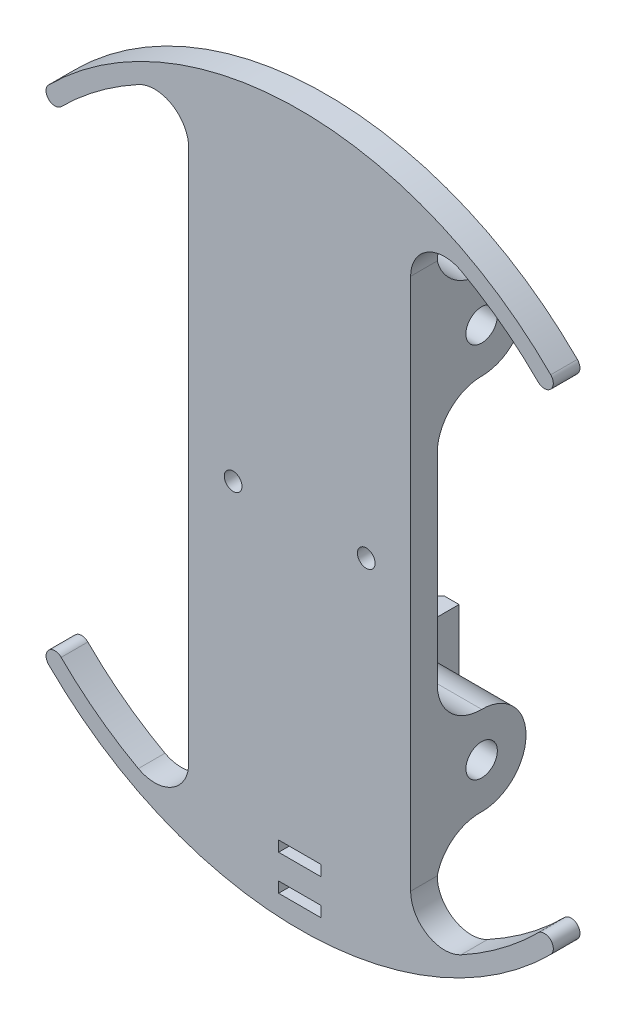
from build123d import *

# Parameters (mm, degrees)
MAIN_BODY_DEPTH                  = 3.81
CROSS_SCREW_BOSSES_DEPTH         = 31.75
F_8_CLEARANCE_HOLE1_D            = 4.4958
BALLOON_MONOFILAMENT_HOLE_D      = 2.5273
PARACHUTE_MONOFILAMENT_HOLE_D    = 2.5273
SKETCH21_W                       = 12.08
SKETCH21_H                       = 11.74
HOT_WIRE_CUTTER_HOLDER_DEPTH     = 9.67
CUT_EXTRUDE10_START              = -1.27
CUT_EXTRUDE10_DEPTH              = 63.383576094
CHAMFER8_SIZE                    = 0.381
SKETCH22_W                       = 6.029522694
SKETCH22_H                       = 1.524
SATELLITE_CABLE_MANAGEMENT_DEPTH = 66.050272386


with BuildPart() as part:
    # Sketch3 → Main body (new body)
    with BuildSketch(Plane.XY):
        with BuildLine():
            Line((-15.875, -38.1), (-15.875, 38.1))
            ThreePointArc((-15.875, 38.1), (-18.260491841, 42.291797068), (-23.082694008, 42.38179842))
            ThreePointArc((-23.082694008, 42.38179842), (-28.900226452, 38.649767283), (-34.12497326, 34.12497326))
            ThreePointArc((-34.12497326, 34.12497326), (-35.921024484, 34.12497326), (-35.921024484, 35.921024484))
            ThreePointArc((-35.921024484, 35.921024484), (0, 50.8), (35.921024484, 35.921024484))
            ThreePointArc((35.921024484, 35.921024484), (35.921024484, 34.12497326), (34.12497326, 34.12497326))
            ThreePointArc((34.12497326, 34.12497326), (28.900226452, 38.649767283), (23.082694008, 42.38179842))
            ThreePointArc((23.082694008, 42.38179842), (18.260491841, 42.291797068), (15.875, 38.1))
            Line((15.875, 38.1), (15.875, -38.1))
            ThreePointArc((15.875, -38.1), (18.260491841, -42.291797068), (23.082694008, -42.38179842))
            ThreePointArc((23.082694008, -42.38179842), (28.900226452, -38.649767283), (34.12497326, -34.12497326))
            ThreePointArc((34.12497326, -34.12497326), (35.921024484, -34.12497326), (35.921024484, -35.921024484))
            ThreePointArc((35.921024484, -35.921024484), (0, -50.8), (-35.921024484, -35.921024484))
            ThreePointArc((-35.921024484, -35.921024484), (-35.921024484, -34.12497326), (-34.12497326, -34.12497326))
            ThreePointArc((-34.12497326, -34.12497326), (-28.900226452, -38.649767283), (-23.082694008, -42.38179842))
            ThreePointArc((-23.082694008, -42.38179842), (-18.260491841, -42.291797068), (-15.875, -38.1))
        make_face()
    extrude(amount=MAIN_BODY_DEPTH)

    # Sketch5 → Cross screw bosses (add)
    with BuildSketch(Plane(origin=(15.875, 0, 0), x_dir=(0, 0, -1), z_dir=(1, 0, 0))):
        with BuildLine():
            Line((0, 38.1), (0, 26.99385))
            Line((0, 26.99385), (0, 14.29385))
            ThreePointArc((0, 14.29385), (1.86498297, 18.77886703), (6.35, 20.64385))
            ThreePointArc((6.35, 20.64385), (12.699998494, 26.998224058), (6.341251887, 33.343843974))
            ThreePointArc((6.341251887, 33.343843974), (2.338844583, 34.612930799), (0, 38.1))
        make_face()
        with BuildLine():
            ThreePointArc((6.261703048, -20.644463916), (1.864650947, -18.840779739), (0, -14.469233029))
            Line((0, -14.469233029), (0, -26.99385))
            Line((0, -26.99385), (0, -38.1))
            ThreePointArc((0, -38.1), (2.217611083, -34.670801888), (6.077775616, -33.338012189))
            ThreePointArc((6.077775616, -33.338012189), (6.213919542, -33.33945129), (6.35, -33.34385))
            ThreePointArc((6.35, -33.34385), (12.7, -26.99385), (6.35, -20.64385))
            ThreePointArc((6.35, -20.64385), (6.305852606, -20.644312569), (6.261703048, -20.644463916))
        make_face()
    extrude(amount=-CROSS_SCREW_BOSSES_DEPTH)

    # 8 Clearance Hole1 (through all)
    with Locations(Plane(origin=(15.875, 0, 0), x_dir=(0, 0, -1), z_dir=(1, 0, 0))):
        with Locations((6.35, 26.99385), (6.35, -26.893399733)):
            Hole(F_8_CLEARANCE_HOLE1_D / 2)

    # Balloon monofilament hole (through all)
    with Locations(Plane.XY.offset(3.81)):
        with Locations((-9.525, 0)):
            Hole(BALLOON_MONOFILAMENT_HOLE_D / 2)

    # Parachute monofilament hole (through all)
    with Locations(Plane.XY.offset(3.81)):
        with Locations((9.525, 0)):
            Hole(PARACHUTE_MONOFILAMENT_HOLE_D / 2)

    # Sketch21 → Hot wire cutter holder (add)
    with BuildSketch(Plane.XY.offset(-8.5979)):
        with Locations((-5.315, -27.056)):
            Rectangle(SKETCH21_W, SKETCH21_H)
    extrude(amount=-HOT_WIRE_CUTTER_HOLDER_DEPTH)

    # Sketch21_10 → Cut-Extrude10 (cut, through all)
    with BuildSketch(Plane.XY.offset(-8.5979).offset(CUT_EXTRUDE10_START)):
        with BuildLine():
            Line((-4.243, -30.386), (-2.315, -30.386))
            ThreePointArc((-2.315, -30.386), (-1.961446609, -30.239553391), (-1.815, -29.886))
            Line((-1.815, -29.886), (-1.815, -24.786))
            Line((-1.815, -24.786), (-1.765, -24.786))
            ThreePointArc((-1.765, -24.786), (-1.623578644, -24.727421356), (-1.565, -24.586))
            Line((-1.565, -24.586), (-1.565, -24.386))
            Line((-1.565, -24.386), (-1.815, -24.386))
            Line((-1.815, -24.386), (-1.815, -21.186))
            Line((-1.815, -21.186), (-8.815, -21.186))
            Line((-8.815, -21.186), (-8.815, -30.386))
            Line((-8.815, -30.386), (-7.418, -30.386))
            Line((-7.418, -30.386), (-7.418, -32.926))
            Line((-7.418, -32.926), (-4.243, -32.926))
            Line((-4.243, -32.926), (-4.243, -30.386))
        make_face()
    extrude(amount=-CUT_EXTRUDE10_DEPTH, mode=Mode.SUBTRACT)

    # Chamfer8
    chamfer8_edges = [part.edges().sort_by_distance(p)[0] for p in [
        (-8.1165, -30.386, -18.2679),
        (-8.815, -25.786, -18.2679),
        (-3.279, -30.386, -18.2679),
        (-1.961446609, -30.239553391, -18.2679),
        (-1.815, -27.336, -18.2679),
    ]]
    chamfer(chamfer8_edges, length=CHAMFER8_SIZE)

    # Sketch22 → satellite cable management (cut, through all)
    with BuildSketch(Plane(origin=(0, 0, 0), x_dir=(-1, 0, 0), z_dir=(0, 0, -1))):
        with Locations((0, -47.038383029)):
            Rectangle(SKETCH22_W, SKETCH22_H)
        with Locations((0, -41.958383029)):
            Rectangle(SKETCH22_W, SKETCH22_H)
    extrude(amount=-SATELLITE_CABLE_MANAGEMENT_DEPTH, mode=Mode.SUBTRACT)


solid = part.part
